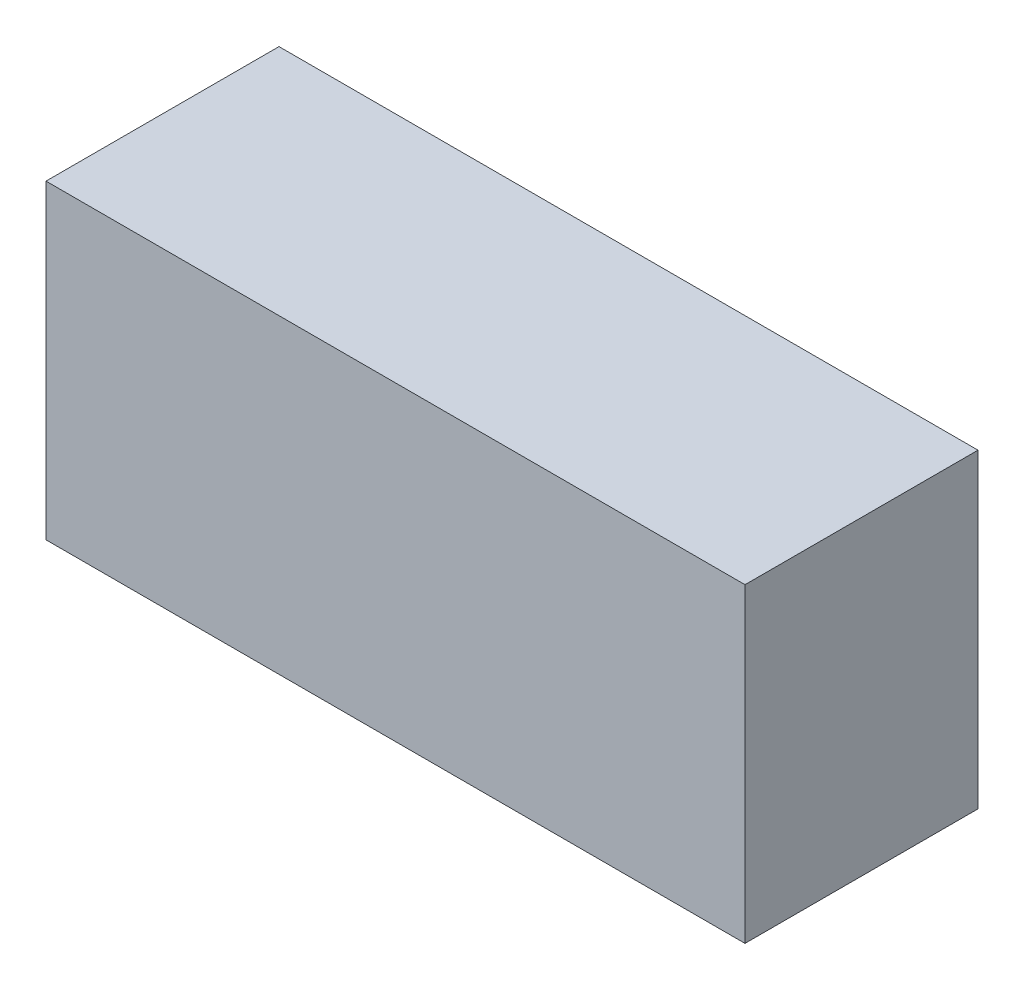
from build123d import *

# Parameters (mm, degrees)
SKETCH1_W           = 9
SKETCH1_H           = 4
BOSS_EXTRUDE1_DEPTH = 3


with BuildPart() as part:
    # Sketch1 → Boss-Extrude1 (new body)
    with BuildSketch(Plane.XY):
        with Locations((-56.340548194, -19.554839833)):
            Rectangle(SKETCH1_W, SKETCH1_H)
    extrude(amount=BOSS_EXTRUDE1_DEPTH)


solid = part.part
